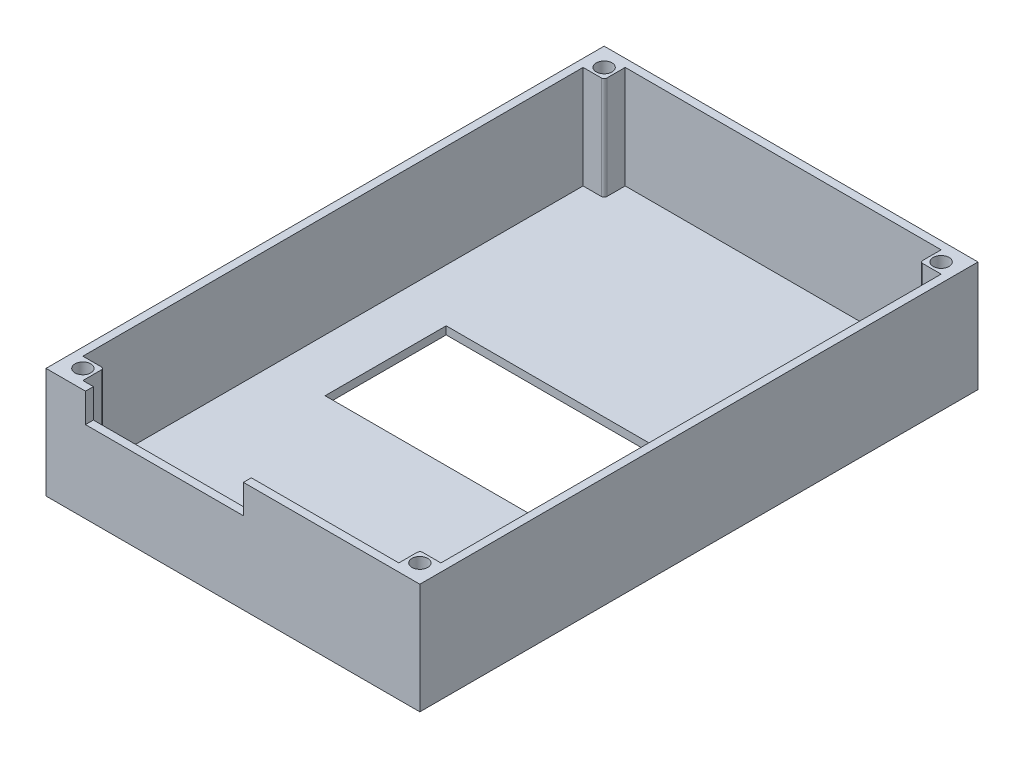
from build123d import *

# Parameters (mm, degrees)
SKETCH2_W                                  = 71
SKETCH2_H                                  = 106
BOSS_EXTRUDE1_DEPTH                        = 21
SHELL1_T                                   = -1.5
SKETCH3_W                                  = 30
SKETCH3_H                                  = 5.5
CUT_EXTRUDE1_DEPTH                         = 21
SKETCH4_R                                  = 1.5
BOSS_EXTRUDE2_DEPTH                        = 19.5
MIRROR1_AT_THE_SECOND_PLANE_COPY_1_SKETC_R = 1.5
MIRROR1_AT_THE_SECOND_PLANE_COPY_1_DEPTH   = 19.5
SKETCH5_W                                  = 48
SKETCH5_H                                  = 23
CUT_EXTRUDE2_DEPTH                         = 1.5


with BuildPart() as part:
    # Sketch2 → Boss-Extrude1 (new body)
    with BuildSketch(Plane(origin=(0, 0, 0), x_dir=(1, 0, 0), z_dir=(0, 1, 0))):
        Rectangle(SKETCH2_W, SKETCH2_H)
    extrude(amount=BOSS_EXTRUDE1_DEPTH)

    # Shell1
    shell1_openings = [part.faces().sort_by_distance(p)[0] for p in [
        (0, 21, 0),
    ]]
    offset(amount=SHELL1_T, openings=shell1_openings, kind=Kind.INTERSECTION)

    # Sketch3 → Cut-Extrude1 (cut)
    with BuildSketch(Plane.XY.offset(53)):
        with Locations((-13, 18.25)):
            Rectangle(SKETCH3_W, SKETCH3_H)
    extrude(amount=-CUT_EXTRUDE1_DEPTH, mode=Mode.SUBTRACT)

    # Sketch4 → Boss-Extrude2 (add)
    with BuildSketch(Plane(origin=(0, 1.5, 0), x_dir=(1, 0, 0), z_dir=(0, 1, 0))):
        with BuildLine():
            Line((-34, 51.5), (-30, 51.5))
            Line((-30, 51.5), (-30, 48))
            ThreePointArc((-30, 48), (-30.146446609, 47.646446609), (-30.5, 47.5))
            Line((-30.5, 47.5), (-34, 47.5))
            Line((-34, 47.5), (-34, 51.5))
        make_face()
        with Locations((-32, 49.5)):
            Circle(SKETCH4_R, mode=Mode.SUBTRACT)
    boss_extrude2 = extrude(amount=BOSS_EXTRUDE2_DEPTH)

    # Mirror1: Boss-Extrude2 across plane
    add(boss_extrude2.mirror(Plane.ZY))

    # Mirror1 at the second plane: Boss-Extrude2 across plane
    add(boss_extrude2.mirror(Plane(origin=(0, 0, 0), x_dir=(1, 0, 0), z_dir=(0, 0, -1))))

    # Mirror1 at the second plane copy 1 sketc → Mirror1 at the second plane copy 1 (add)
    with BuildSketch(Plane(origin=(0, 1.5, 0), x_dir=(-1, 0, 0), z_dir=(0, 1, 0))):
        with BuildLine():
            Line((-34, 51.5), (-30, 51.5))
            Line((-30, 51.5), (-30, 48))
            ThreePointArc((-30, 48), (-30.146446609, 47.646446609), (-30.5, 47.5))
            Line((-30.5, 47.5), (-34, 47.5))
            Line((-34, 47.5), (-34, 51.5))
        make_face()
        with Locations((-32, 49.5)):
            Circle(MIRROR1_AT_THE_SECOND_PLANE_COPY_1_SKETC_R, mode=Mode.SUBTRACT)
    extrude(amount=MIRROR1_AT_THE_SECOND_PLANE_COPY_1_DEPTH)

    # Sketch5 → Cut-Extrude2 (cut)
    with BuildSketch(Plane(origin=(0, 1.5, 0), x_dir=(1, 0, 0), z_dir=(0, 1, 0))):
        Rectangle(SKETCH5_W, SKETCH5_H)
    extrude(amount=-CUT_EXTRUDE2_DEPTH, mode=Mode.SUBTRACT)


solid = part.part
